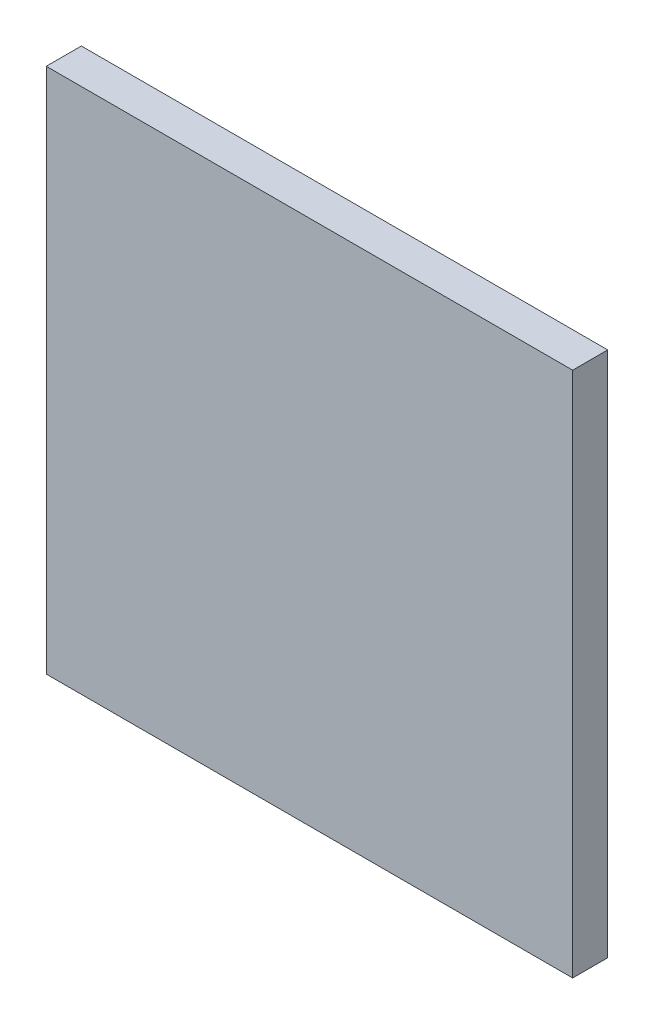
from build123d import *

# Parameters (mm, degrees)
ESQUISSE1_W        = 30
ESQUISSE1_H        = 30
BOSS_EXTRU_1_DEPTH = 2


with BuildPart() as part:
    # Esquisse1 → Boss.-Extru.1 (new body)
    with BuildSketch(Plane.XY):
        Rectangle(ESQUISSE1_W, ESQUISSE1_H)
    extrude(amount=BOSS_EXTRU_1_DEPTH)


solid = part.part
